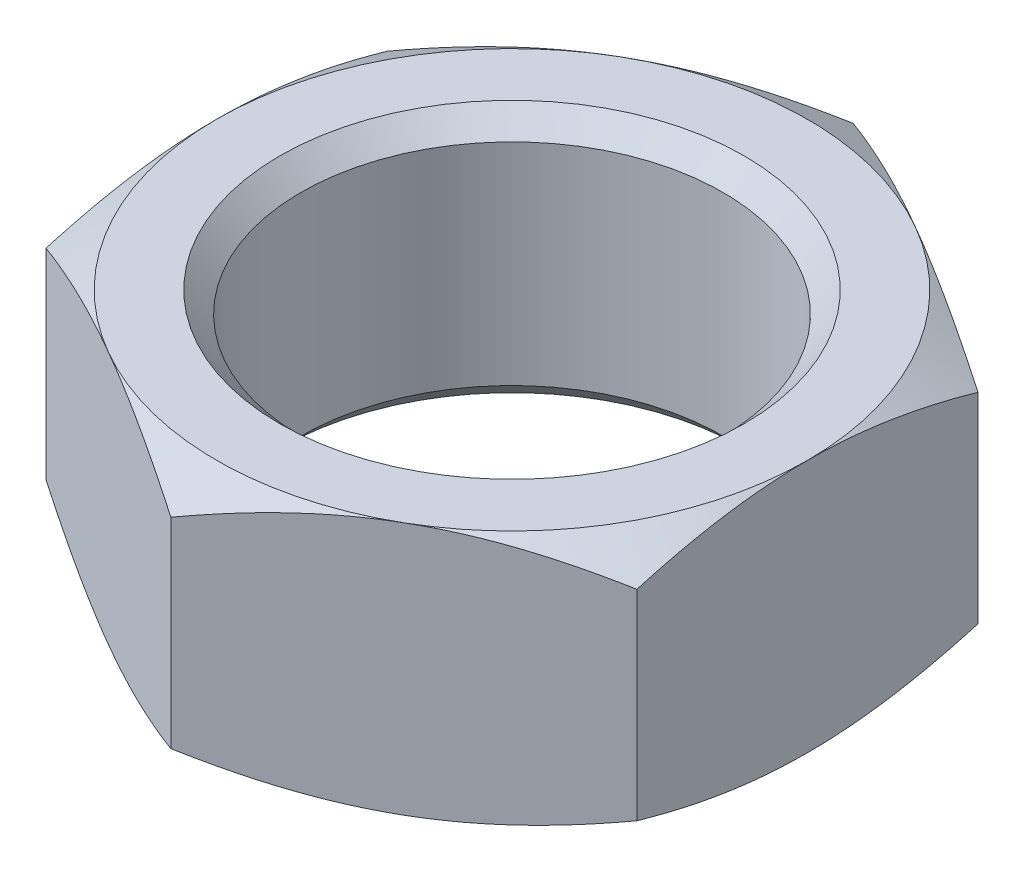
from build123d import *

# Parameters (mm, degrees)
BOSS_EXTRUDE1_DEPTH = 6
SKETCH2_OUTSIDE_W   = 80.454
SKETCH2_OUTSIDE_H   = 84.786
SKETCH2_OUTSIDE_R   = 14
CUT_EXTRUDE1_DEPTH  = 12
CUT_EXTRUDE1_TAPER  = 60
SKETCH3_R           = 10
CUT_EXTRUDE2_DEPTH  = 13
CHAMFER1_SIZE       = 1


with BuildPart() as part:
    # Sketch1 → Boss-Extrude1 (new body, symmetric)
    with BuildSketch(Plane(origin=(0, 0, 0), x_dir=(1, 0, 0), z_dir=(0, 1, 0))):
        Polygon((0, -16.165807537), (14, -8.082903769), (14, 8.082903769), (0, 16.165807537), (-14, 8.082903769), (-14, -8.082903769), align=None)
    extrude(amount=BOSS_EXTRUDE1_DEPTH, both=True)

    # Sketch2 outside → Cut-Extrude1 (cut)
    with BuildSketch(Plane(origin=(0, 6, 0), x_dir=(1, 0, 0), z_dir=(0, 1, 0))):
        Rectangle(SKETCH2_OUTSIDE_W, SKETCH2_OUTSIDE_H)
        Circle(SKETCH2_OUTSIDE_R, mode=Mode.SUBTRACT)
    cut_extrude1 = extrude(amount=-CUT_EXTRUDE1_DEPTH, taper=CUT_EXTRUDE1_TAPER, mode=Mode.SUBTRACT)

    # Mirror1: Cut-Extrude1 across plane
    add(cut_extrude1.mirror(Plane.ZX), mode=Mode.SUBTRACT)

    # Sketch3 → Cut-Extrude2 (cut, through all)
    with BuildSketch(Plane(origin=(0, 6, 0), x_dir=(1, 0, 0), z_dir=(0, 1, 0))):
        Circle(SKETCH3_R)
    extrude(amount=-CUT_EXTRUDE2_DEPTH, mode=Mode.SUBTRACT)

    # Chamfer1
    chamfer1_edges = [part.edges().sort_by_distance(p)[0] for p in [
        (-10, -6, 0),
        (-10, 6, 0),
    ]]
    chamfer(chamfer1_edges, length=CHAMFER1_SIZE)


solid = part.part
